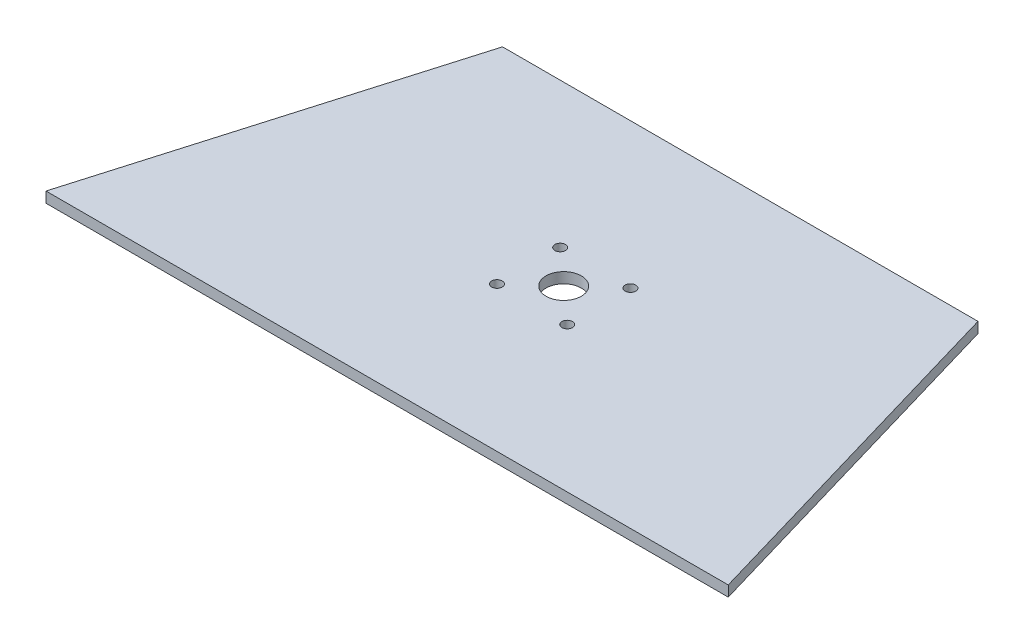
from build123d import *

# Parameters (mm, degrees)
BOSS_EXTRUDE1_DEPTH        = 3
F_10_0MM_DOWEL_HOLE1_D     = 10
F_10_0MM_DOWEL_HOLE1_DEPTH = 3
F_3_0MM_DOWEL_HOLE1_D      = 3
F_3_0MM_DOWEL_HOLE1_DEPTH  = 3


with BuildPart() as part:
    # Sketch1 → Boss-Extrude1 (new body)
    with BuildSketch(Plane(origin=(0, 0, 0), x_dir=(1, 0, 0), z_dir=(0, 1, 0))):
        Polygon((-13.2, 0), (180, 0), (150.720058283, 100), (16.079941717, 100), align=None)
    extrude(amount=BOSS_EXTRUDE1_DEPTH)

    # Ø10.0mm Dowel Hole1
    with Locations(Plane(origin=(0, 3, 0), x_dir=(1, 0, 0), z_dir=(0, 1, 0))):
        with Locations((83.4, 50)):
            Hole(F_10_0MM_DOWEL_HOLE1_D / 2, depth=F_10_0MM_DOWEL_HOLE1_DEPTH)

    # Ø3.0mm Dowel Hole1
    with Locations(Plane(origin=(0, 3, 0), x_dir=(1, 0, 0), z_dir=(0, 1, 0))):
        with Locations((73.45, 58.95), (73.45, 41.05), (93.35, 41.05), (93.35, 58.95)):
            Hole(F_3_0MM_DOWEL_HOLE1_D / 2, depth=F_3_0MM_DOWEL_HOLE1_DEPTH)


solid = part.part
